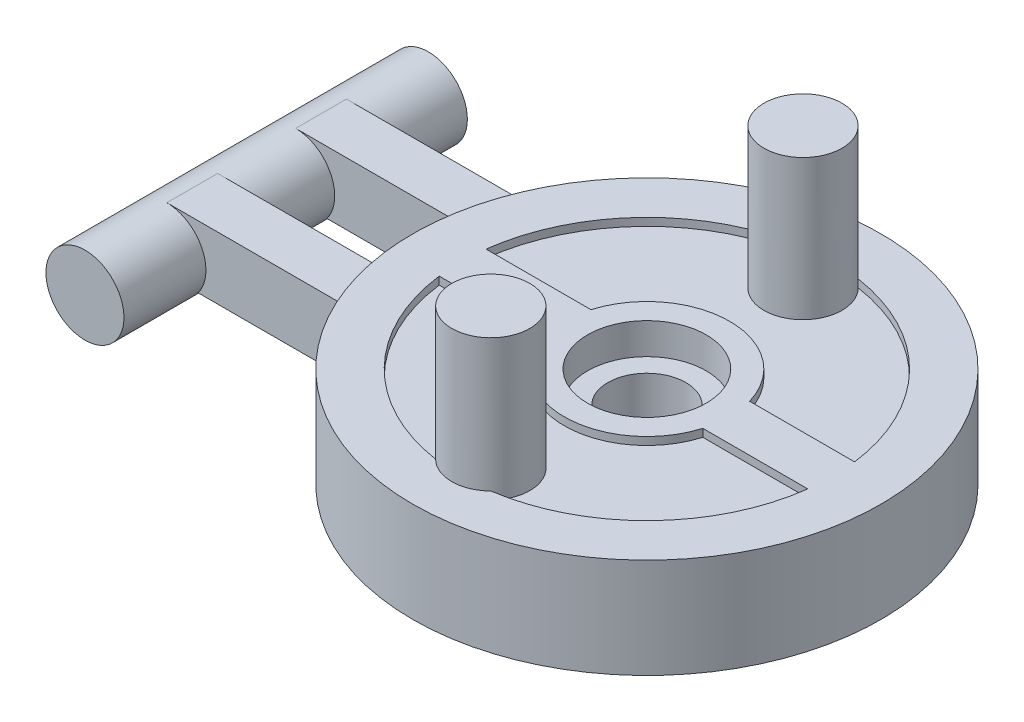
from build123d import *

# Parameters (mm, degrees)
SKETCH1_R           = 15
BOSS_EXTRUDE1_DEPTH = 6.4
CUT_EXTRUDE1_DEPTH  = 0.5
SKETCH3_R           = 2.5
BOSS_EXTRUDE2_DEPTH = 9
SKETCH4_R           = 3.8
CUT_EXTRUDE2_DEPTH  = 2
SKETCH6_R           = 4
BOSS_EXTRUDE3_DEPTH = 1
SKETCH5_R           = 2.5
CUT_EXTRUDE3_DEPTH  = 6.4
SKETCH8_W           = 12
SKETCH8_H           = 3.25
BOSS_EXTRUDE4_DEPTH = 4
SKETCH9_R           = 2.5
BOSS_EXTRUDE6_DEPTH = 11


with BuildPart() as part:
    # Sketch1 → Boss-Extrude1 (new body)
    with BuildSketch(Plane(origin=(0, 0, 0), x_dir=(1, 0, 0), z_dir=(0, 1, 0))):
        Circle(SKETCH1_R)
    extrude(amount=BOSS_EXTRUDE1_DEPTH)

    # Sketch2 → Cut-Extrude1 (cut)
    with BuildSketch(Plane(origin=(0, 6.4, 0), x_dir=(1, 0, 0), z_dir=(0, 1, 0))):
        with BuildLine():
            ThreePointArc((-5.083306011, -1.5), (0, -5.3), (5.083306011, -1.5))
            Line((5.083306011, -1.5), (11.805083651, -1.5))
            ThreePointArc((11.805083651, -1.5), (0, -11.9), (-11.805083651, -1.5))
            Line((-11.805083651, -1.5), (-5.083306011, -1.5))
        make_face()
        with BuildLine():
            Line((-11.805083651, 1.5), (-5.083306011, 1.5))
            ThreePointArc((-5.083306011, 1.5), (0, 5.3), (5.083306011, 1.5))
            Line((5.083306011, 1.5), (11.805083651, 1.5))
            ThreePointArc((11.805083651, 1.5), (0, 11.9), (-11.805083651, 1.5))
        make_face()
    extrude(amount=-CUT_EXTRUDE1_DEPTH, mode=Mode.SUBTRACT)

    # Sketch3 → Boss-Extrude2 (add)
    with BuildSketch(Plane(origin=(0, 5.9, 0), x_dir=(1, 0, 0), z_dir=(0, 1, 0))):
        with Locations((0, -10)):
            Circle(SKETCH3_R)
        with Locations((0, 10)):
            Circle(SKETCH3_R)
    extrude(amount=BOSS_EXTRUDE2_DEPTH)

    # Sketch4 → Cut-Extrude2 (cut)
    with BuildSketch(Plane(origin=(0, 6.4, 0), x_dir=(1, 0, 0), z_dir=(0, 1, 0))):
        Circle(SKETCH4_R)
    extrude(amount=-CUT_EXTRUDE2_DEPTH, mode=Mode.SUBTRACT)

    # Sketch6 → Boss-Extrude3 (add)
    with BuildSketch(Plane.XZ):
        Circle(SKETCH6_R)
    extrude(amount=BOSS_EXTRUDE3_DEPTH)

    # Sketch5 → Cut-Extrude3 (cut, through all)
    with BuildSketch(Plane(origin=(0, 4.4, 0), x_dir=(1, 0, 0), z_dir=(0, 1, 0))):
        Circle(SKETCH5_R)
    extrude(amount=-CUT_EXTRUDE3_DEPTH, mode=Mode.SUBTRACT)

    # Sketch8 → Boss-Extrude4 (add)
    with BuildSketch(Plane(origin=(0, 2, 0), x_dir=(1, 0, 0), z_dir=(0, 1, 0))):
        with Locations((-19, 4.125)):
            Rectangle(SKETCH8_W, SKETCH8_H)
        with Locations((-19, -4.125)):
            Rectangle(SKETCH8_W, SKETCH8_H)
    extrude(amount=BOSS_EXTRUDE4_DEPTH)

    # Sketch9 → Boss-Extrude6 (add, symmetric)
    with BuildSketch(Plane.XY):
        with Locations((-25, 3.5)):
            Circle(SKETCH9_R)
    extrude(amount=BOSS_EXTRUDE6_DEPTH, both=True)


solid = part.part
